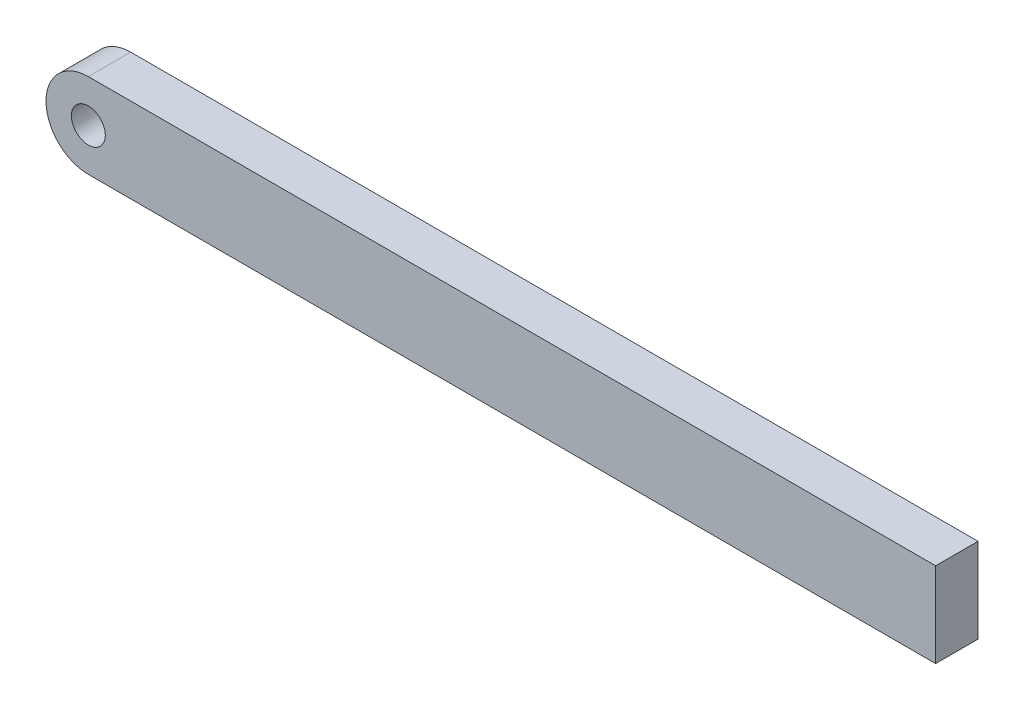
from build123d import *

# Parameters (mm, degrees)
EXTRUDE_1_DEPTH     = 50
SKETCH_2_R          = 20
CUT_EXTRUDE_1_DEPTH = 30


with BuildPart() as part:
    # 草图1 → 凸台-拉伸1 (new body)
    with BuildSketch(Plane.XY):
        with BuildLine():
            Line((0, 50), (1000, 50))
            Line((1000, 50), (1000, -50))
            Line((1000, -50), (0, -50))
            ThreePointArc((0, -50), (-50, 0), (0, 50))
        make_face()
    extrude(amount=EXTRUDE_1_DEPTH)

    # 草图2 → 切除-拉伸1 (cut)
    with BuildSketch(Plane.XY.offset(50)):
        Circle(SKETCH_2_R)
    extrude(amount=-CUT_EXTRUDE_1_DEPTH, mode=Mode.SUBTRACT)


solid = part.part
